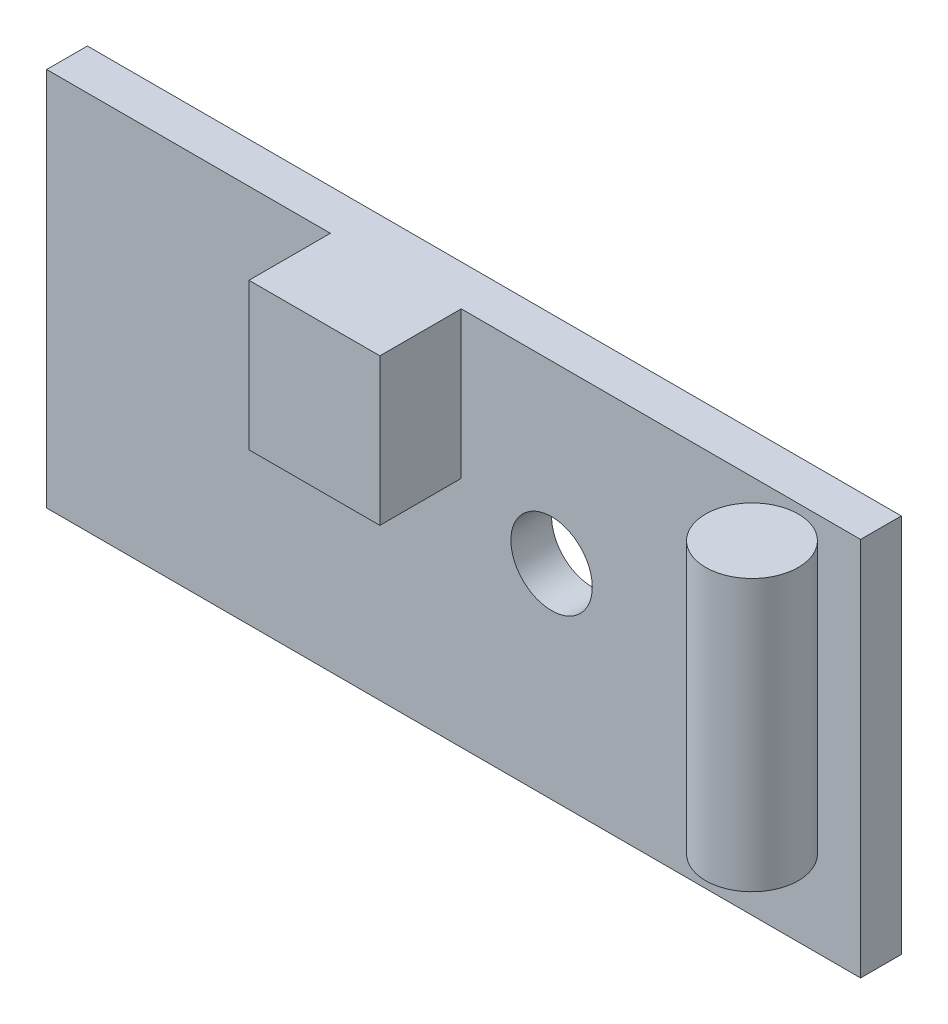
from build123d import *

# Parameters (mm, degrees)
SKETCH1_W           = 30
SKETCH1_H           = 14
SKETCH1_R           = 1.5
BOSS_EXTRUDE1_DEPTH = 1.5
SKETCH2_W           = 4.823839664
SKETCH2_H           = 5.412112793
BOSS_EXTRUDE2_DEPTH = 3
SKETCH3_R           = 1.706533857
BOSS_EXTRUDE3_DEPTH = 10


with BuildPart() as part:
    # Sketch1 → Boss-Extrude1 (new body)
    with BuildSketch(Plane.XY):
        with Locations((171.518802712, 81.184347227)):
            Rectangle(SKETCH1_W, SKETCH1_H)
        with Locations((175.128446175, 81.715874023)):
            Circle(SKETCH1_R, mode=Mode.SUBTRACT)
    extrude(amount=BOSS_EXTRUDE1_DEPTH)

    # Sketch2 → Boss-Extrude2 (add)
    with BuildSketch(Plane.XY.offset(1.5)):
        with Locations((169.386934045, 85.478290831)):
            Rectangle(SKETCH2_W, SKETCH2_H)
    extrude(amount=BOSS_EXTRUDE2_DEPTH)


with BuildPart() as body_2:
    # Sketch3 → Boss-Extrude3 (new body)
    with BuildSketch(Plane(origin=(0, 88.184347227, 0), x_dir=(1, 0, 0), z_dir=(0, 1, 0))):
        with Locations((184.559078961, -3.543177059)):
            Circle(SKETCH3_R)
    extrude(amount=-BOSS_EXTRUDE3_DEPTH)


solid = Compound([part.part, body_2.part])
